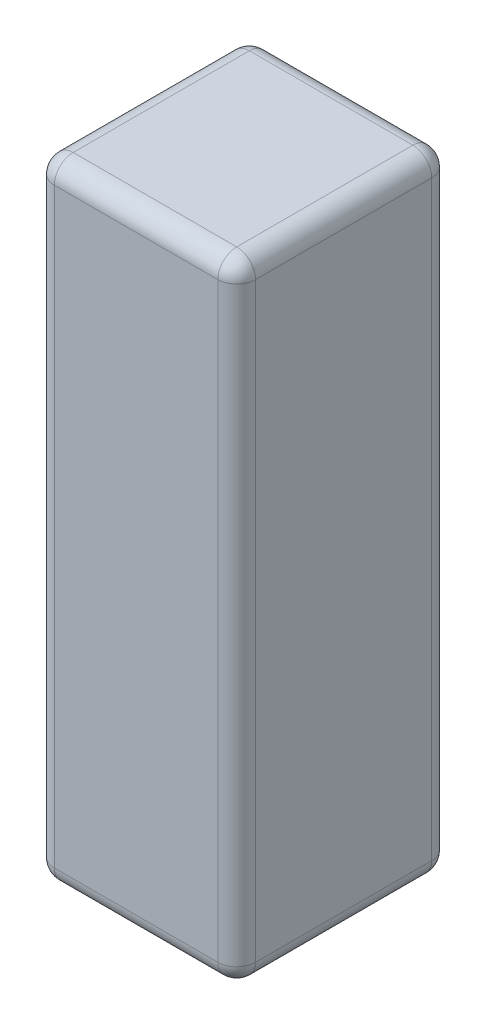
from build123d import *

# Parameters (mm, degrees)
SKETCH1_W           = 32
SKETCH1_H           = 100
BOSS_EXTRUDE1_DEPTH = 34
FILLET1_R           = 3


with BuildPart() as part:
    # Sketch1 → Boss-Extrude1 (new body)
    with BuildSketch(Plane.XY):
        with Locations((46.306042722, -47.349420118)):
            Rectangle(SKETCH1_W, SKETCH1_H)
    extrude(amount=BOSS_EXTRUDE1_DEPTH)

    # Fillet1
    fillet1_edges = [part.edges().sort_by_distance(p)[0] for p in [
        (62.306042722, -47.349420118, 34),
        (46.306042722, 2.650579882, 34),
        (30.306042722, -47.349420118, 34),
        (46.306042722, 2.650579882, 0),
        (62.306042722, -47.349420118, 0),
        (46.306042722, -97.349420118, 0),
        (30.306042722, -47.349420118, 0),
        (30.306042722, 2.650579882, 17),
        (62.306042722, 2.650579882, 17),
        (62.306042722, -97.349420118, 17),
        (30.306042722, -97.349420118, 17),
        (46.306042722, -97.349420118, 34),
    ]]
    fillet(fillet1_edges, radius=FILLET1_R)


solid = part.part
